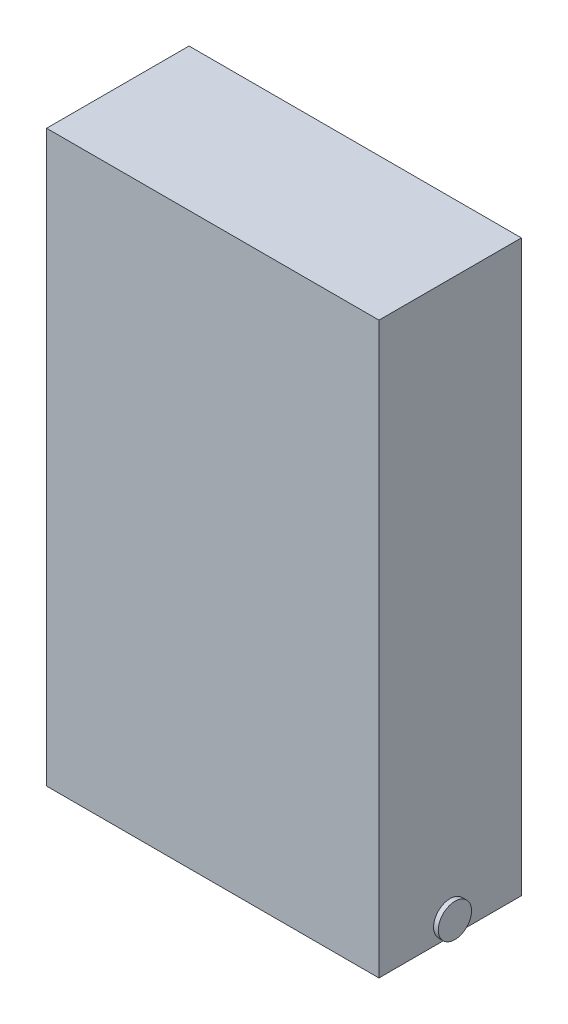
from build123d import *

# Parameters (mm, degrees)
SZKIC1_W                    = 350
SZKIC1_H                    = 600
DODANIE_WYCI_GNI_CIE1_DEPTH = 150
WYTNIJ_WYCI_GNI_CIE1_START  = -2.5
SZKIC2_W                    = 300
SZKIC2_H                    = 250
WYTNIJ_WYCI_GNI_CIE1_DEPTH  = 100
SZKIC3_R                    = 17.5
DODANIE_WYCI_GNI_CIE2_DEPTH = 5


with BuildPart() as part:
    # Szkic1 → Dodanie-wyciągnięcie1 (new body)
    with BuildSketch(Plane.XY):
        with Locations((175, 300)):
            Rectangle(SZKIC1_W, SZKIC1_H)
    extrude(amount=DODANIE_WYCI_GNI_CIE1_DEPTH)

    # Szkic2 → Wytnij-wyciągnięcie1 (cut)
    with BuildSketch(Plane(origin=(0, 0, 0), x_dir=(-1, 0, 0), z_dir=(0, 0, -1)).offset(WYTNIJ_WYCI_GNI_CIE1_START)):
        with Locations((-175, 150)):
            Rectangle(SZKIC2_W, SZKIC2_H)
    extrude(amount=-WYTNIJ_WYCI_GNI_CIE1_DEPTH, mode=Mode.SUBTRACT)

    # Szkic3 → Dodanie-wyciągnięcie2 (add)
    with BuildSketch(Plane(origin=(350, 0, 0), x_dir=(0, 0, -1), z_dir=(1, 0, 0))):
        with Locations((-75, 17.5)):
            Circle(SZKIC3_R)
    dodanie_wyci_gni_cie2 = extrude(amount=DODANIE_WYCI_GNI_CIE2_DEPTH)

    # Lustro1: Dodanie-wyciągnięcie2 across plane
    add(dodanie_wyci_gni_cie2.mirror(Plane.ZY.offset(-175)))


solid = part.part
